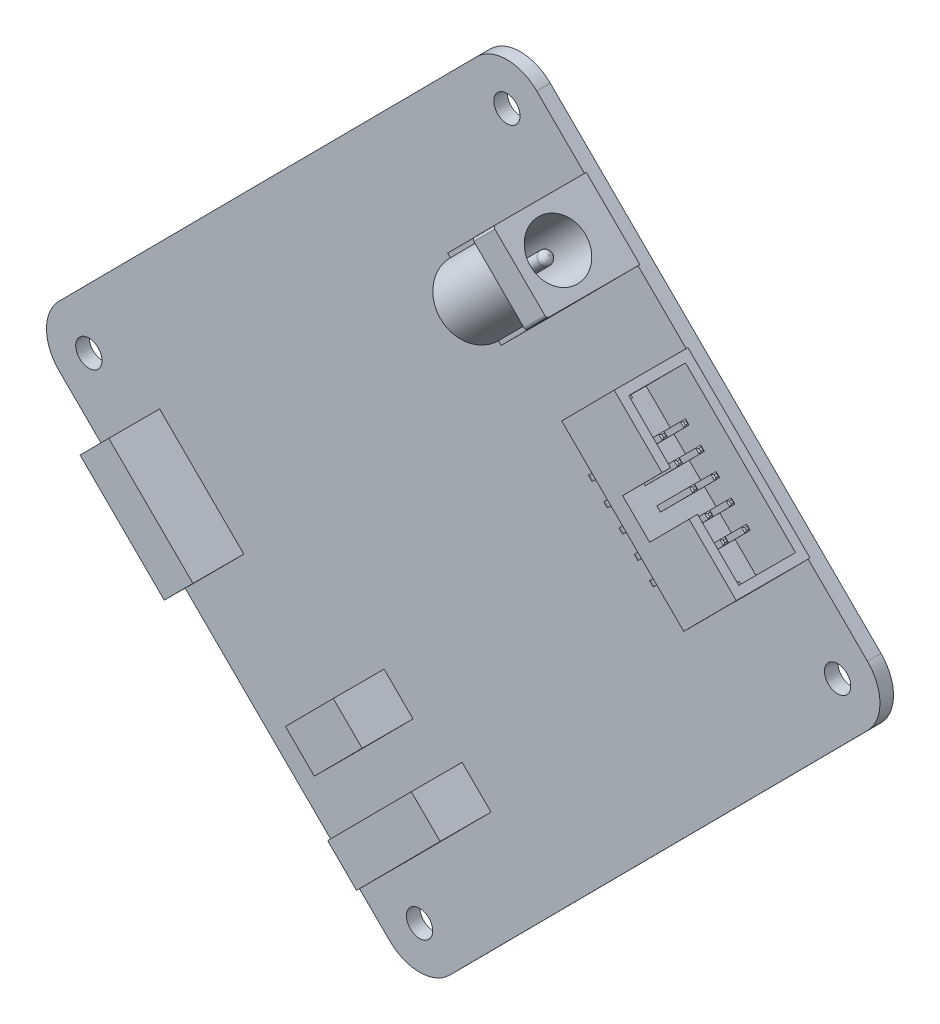
from build123d import *

# Parameters (mm, degrees)
EXTRUDE_1_DEPTH      = 1.6
SKETCH_2_R           = 1.5500000000000003
SKETCH_2_R_2         = 1.5500000000000012
SKETCH_2_R_3         = 1.550000000000001
CUT_EXTRUDE_1_DEPTH  = 1.6
EXTRUDE_2_DEPTH      = 8.7
CUT_EXTRUDE_2_DEPTH  = 6.6
CUT_EXTRUDE_3_DEPTH  = 1.3
CUT_EXTRUDE_4_DEPTH  = 1.3
EXTRUDE_3_DEPTH      = 5.6
EXTRUDE_3_DEPTH_BACK = 4.2
SKETCH_7_W           = 0.6000000000000014
SKETCH_7_H           = 0.5999999999999988
SKETCH_7_W_2         = 0.5999999999999996
SKETCH_7_W_3         = 0.6000000000000001
SKETCH_7_H_2         = 0.5999999999999996
SKETCH_8_W           = 0.6000000000000001
SKETCH_8_H           = 0.5999999999999988
SKETCH_8_W_2         = 0.599999999999997
SKETCH_8_W_3         = 0.5999999999999996
SKETCH_8_W_4         = 0.5999999999999979
EXTRUDE_4_DEPTH      = 2.54
EXTRUDE_5_DEPTH      = 3.06
EXTRUDE_6_DEPTH      = 5.6
FILLET_2_R           = 0.6
CHAMFER_1_SIZE       = 0.15
EXTRUDE_7_DEPTH      = 6
EXTRUDE_8_DEPTH      = 6
EXTRUDE_9_DEPTH      = 11
CUT_EXTRUDE_5_DEPTH  = 10.5
FILLET_3_R           = 0.3
SKETCH_16_R          = 3.2500000000000004
CUT_EXTRUDE_6_DEPTH  = 11.500000000000004
SKETCH_17_R          = 0.7500000000000004
EXTRUDE_10_DEPTH     = 10
FILLET_4_R           = 0.7


with BuildPart() as part:
    # 草图1 → 凸台-拉伸1 (new body)
    with BuildSketch(Plane.XY):
        with BuildLine():
            Line((-46.21911451091363, -2.6230867480424327), (3.1094757757567852, 47.04269805729206))
            ThreePointArc((3.1094757757567852, 47.04269805729206), (6.640000938228831, 48.51919831730715), (10.18050256804291, 47.06678338005377))
            Line((10.18050256804291, 47.06678338005377), (49.20361920080571, 8.30860529766987))
            ThreePointArc((49.20361920080571, 8.30860529766987), (50.680119460820805, 4.778080135197828), (49.22770452356743, 1.2375785053837478))
            Line((49.22770452356743, 1.2375785053837478), (-0.10088576310299377, -48.42820629995073))
            ThreePointArc((-0.10088576310299377, -48.42820629995073), (-3.6314109255750346, -49.904706559965824), (-7.171912555389116, -48.45229162271245))
            Line((-7.171912555389116, -48.45229162271245), (-46.195029188151906, -9.694113540328557))
            ThreePointArc((-46.195029188151906, -9.694113540328557), (-47.671529448167, -6.163588377856511), (-46.21911451091363, -2.6230867480424327))
        make_face()
    extrude(amount=EXTRUDE_1_DEPTH)

    # 草图2 → 切除-拉伸1 (cut)
    with BuildSketch(Plane.XY.offset(1.6)):
        with Locations((6.657031833280706, 43.51922732252991)):
            Circle(SKETCH_2_R)
        with Locations((-42.671558453389764, -6.146557482804635)):
            Circle(SKETCH_2_R_2)
        with Locations((-3.648441820626913, -44.90473556518859)):
            Circle(SKETCH_2_R_3)
        with Locations((45.68014846604356, 4.76104924014595)):
            Circle(SKETCH_2_R_2)
    extrude(amount=-CUT_EXTRUDE_1_DEPTH, mode=Mode.SUBTRACT)

    # 草图3 → 凸台-拉伸2 (add)
    with BuildSketch(Plane.XY.offset(1.6)):
        Polygon((28.02326441802238, 29.767987191737213), (21.82195592484095, 23.524288530495152), (36.22503351838797, 9.218997347360718), (42.426342011569396, 15.462696008602775), align=None)
    extrude(amount=EXTRUDE_2_DEPTH)

    # 草图4 → 切除-拉伸2 (cut)
    with BuildSketch(Plane(origin=(28.799828733701656, 28.996695182368285, 0), x_dir=(0.7095112115047791, -0.7046941469524354, 0), z_dir=(0.7046941469524354, 0.7095112115047791, 0))):
        Polygon((18.205493946977548, -9.299999999999999), (11.35549394697755, -9.299999999999999), (11.35549394697755, -10.3), (6.855493946977551, -10.3), (6.855493946977551, -9.299999999999999), (-0.09450605302244955, -9.299999999999999), (-0.09450605302244955, -2.6), (18.205493946977548, -2.6), align=None)
    extrude(amount=-CUT_EXTRUDE_2_DEPTH, mode=Mode.SUBTRACT)

    # 草图5 → 切除-拉伸3 (cut)
    with BuildSketch(Plane(origin=(13.626513277867756, -13.533999173765512, 0), x_dir=(0, 0, -1), z_dir=(0.7095112115047784, -0.7046941469524362, 0))):
        Polygon((-7.8, 32.06855107034904), (-7.800000000000001, 38.56855107034904), (-4.400000000000001, 38.56855107034904), (-4.4, 32.06855107034904), align=None)
    extrude(amount=-CUT_EXTRUDE_3_DEPTH, mode=Mode.SUBTRACT)

    # 草图6 → 切除-拉伸4 (cut)
    with BuildSketch(Plane(origin=(-0.7765643156792579, 0.7712920093689172, 0), x_dir=(0, 0, 1), z_dir=(-0.7095112115047795, 0.7046941469524352, 0))):
        Polygon((7.8, 32.06855107034904), (4.4, 32.06855107034904), (4.3999999999999995, 38.56855107034904), (7.8, 38.56855107034904), align=None)
    extrude(amount=-CUT_EXTRUDE_4_DEPTH, mode=Mode.SUBTRACT)

    # 草图7 → 凸台-拉伸3 (add, two sides: drawn at the far end of the back side and taken through both)
    with BuildSketch(Plane(origin=(24.148847363815584, 24.313921186436747, 0), x_dir=(0.7095112115047791, -0.7046941469524355, 0), z_dir=(0.7046941469524355, 0.7095112115047791, 0)).offset(-EXTRUDE_3_DEPTH_BACK)):
        with Locations((14.405493946977552, -7.5)):
            Rectangle(SKETCH_7_W, SKETCH_7_H)
        with Locations((11.865493946977551, -7.5)):
            Rectangle(SKETCH_7_W_2, SKETCH_7_H)
        with Locations((9.325493946977552, -7.5)):
            Rectangle(SKETCH_7_W_2, SKETCH_7_H)
        with Locations((6.785493946977553, -7.5)):
            Rectangle(SKETCH_7_W_2, SKETCH_7_H)
        with Locations((4.245493946977553, -7.5)):
            Rectangle(SKETCH_7_W_3, SKETCH_7_H)
        with Locations((11.865493946977551, -4.96)):
            Rectangle(SKETCH_7_W_2, SKETCH_7_H_2)
        with Locations((9.325493946977552, -4.96)):
            Rectangle(SKETCH_7_W_2, SKETCH_7_H_2)
        with Locations((6.785493946977553, -4.96)):
            Rectangle(SKETCH_7_W_2, SKETCH_7_H_2)
        with Locations((4.245493946977553, -4.96)):
            Rectangle(SKETCH_7_W_3, SKETCH_7_H_2)
        with Locations((14.405493946977552, -4.96)):
            Rectangle(SKETCH_7_W, SKETCH_7_H_2)
    extrude(amount=EXTRUDE_3_DEPTH + EXTRUDE_3_DEPTH_BACK)

    # 草图8 → 凸台-拉伸4 (add)
    with BuildSketch(Plane(origin=(21.18913194661535, 21.333974098116673, 0), x_dir=(0.7095112115047791, -0.7046941469524355, 0), z_dir=(-0.7046941469524355, -0.7095112115047791, 0))):
        with Locations((4.245493946977553, 7.5)):
            Rectangle(SKETCH_8_W, SKETCH_8_H)
        with Locations((6.785493946977555, 7.5)):
            Rectangle(SKETCH_8_W_2, SKETCH_8_H)
        with Locations((9.325493946977549, 7.5)):
            Rectangle(SKETCH_8_W_3, SKETCH_8_H)
        with Locations((11.865493946977551, 7.5)):
            Rectangle(SKETCH_8_W_4, SKETCH_8_H)
        with Locations((14.405493946977547, 7.5)):
            Rectangle(SKETCH_8_W_3, SKETCH_8_H)
    extrude(amount=EXTRUDE_4_DEPTH)

    # 草图9 → 凸台-拉伸5 (add)
    with BuildSketch(Plane(origin=(0, 0, 4.66), x_dir=(-1, 0, -2.05e-15), z_dir=(2.05e-15, -2.04e-15, -1))):
        Polygon((-31.622844772711588, 10.971098585637124), (-31.19713804580872, 11.393915073808587), (-31.62284477271158, 11.822531796193495), (-32.04855149961444, 11.399715308022037), align=None)
        Polygon((-29.82068629548945, 12.761021718896309), (-29.39497956858658, 13.183838207067769), (-29.820686295489466, 13.6124549294527), (-30.24639302239233, 13.18963844128124), align=None)
        Polygon((-28.01852781826731, 14.550944852155498), (-27.592821091364442, 14.973761340326956), (-28.018527818267312, 15.402378062711874), (-28.44423454517018, 14.979561574540412), align=None)
        Polygon((-26.216369341045173, 16.340867985414683), (-25.790662614142306, 16.763684473586142), (-26.21636934104517, 17.19230119597105), (-26.64207606794803, 16.769484707799588), align=None)
        Polygon((-24.414210863823033, 18.130791118673862), (-23.988504136920163, 18.553607606845326), (-24.414210863823044, 18.982224329230252), (-24.83991759072591, 18.559407841058793), align=None)
    extrude(amount=EXTRUDE_5_DEPTH)

    # 草图10 → 凸台-拉伸6 (add)
    with BuildSketch(Plane(origin=(0, 0, 7.2), x_dir=(-1, 0, -1.03e-15), z_dir=(1.03e-15, -1.02e-15, -1))):
        Polygon((-29.832921639452397, 9.16894010841499), (-29.40721491254953, 9.591756596586453), (-29.832921639452394, 10.020373318971362), (-30.258628366355257, 9.597556830799897), align=None)
        Polygon((-28.03076316223028, 10.958863241674191), (-27.605056435327413, 11.38167972984565), (-28.030763162230265, 11.810296452230556), (-28.456469889133132, 11.387479964059093), align=None)
        Polygon((-26.22860468500812, 12.748786374933355), (-25.80289795810525, 13.171602863104818), (-26.228604685008126, 13.60021958548974), (-26.654311411910996, 13.17740309731828), align=None)
        Polygon((-24.42644620778598, 14.538709508192541), (-24.00073948088312, 14.961525996363997), (-24.42644620778599, 15.39014271874892), (-24.852152934688856, 14.967326230577465), align=None)
        Polygon((-22.624287730563847, 16.32863264145173), (-22.19858100366098, 16.751449129623193), (-22.624287730563854, 17.180065852008116), (-23.04999445746672, 16.757249363836653), align=None)
    extrude(amount=EXTRUDE_6_DEPTH)

    # 圆角2
    fillet_2_edges = [part.edges().sort_by_distance(p)[0] for p in [
        (29.607832932038022, 12.97242996298204, 5.26),
        (27.805674454815883, 14.762353096241227, 5.26),
        (26.003515977593743, 16.552276229500414, 5.26),
        (24.201357500371603, 18.342199362759597, 5.26),
        (31.409991409260158, 11.182506829722856, 5.26),
        (22.411434367112413, 16.540040885537458, 7.8),
        (24.213592844334556, 14.750117752278271, 7.8),
        (26.01575132155669, 12.96019461901909, 7.8),
        (27.817909798778828, 11.170271485759901, 7.8),
        (29.620068276000964, 9.380348352500718, 7.8),
    ]]
    fillet(fillet_2_edges, radius=FILLET_2_R)

    # 倒角1
    chamfer_1_edges = [part.edges().sort_by_distance(p)[0] for p in [
        (38.31599404939403, 18.135716702469693, 7.8),
        (38.10314068594259, 18.34712494655542, 7.5),
        (38.31599404939403, 18.135716702469693, 7.2),
        (38.52884741284546, 17.924308458383962, 7.5),
        (36.300982208720455, 20.137048079814605, 7.5),
        (36.513835572171885, 19.925639835728877, 7.2),
        (36.72668893562332, 19.71423159164315, 7.5),
        (36.513835572171885, 19.925639835728877, 7.8),
        (34.49882373149832, 21.92697121307379, 7.5),
        (34.71167709494975, 21.715562968988063, 7.2),
        (34.924530458401186, 21.50415472490233, 7.5),
        (34.71167709494975, 21.715562968988063, 7.8),
        (32.696665254276176, 23.716894346332978, 7.5),
        (32.90951861772761, 23.505486102247247, 7.2),
        (33.12237198117904, 23.29407785816152, 7.5),
        (32.90951861772761, 23.505486102247247, 7.8),
        (30.894506777054037, 25.506817479592165, 7.5),
        (31.10736014050547, 25.295409235506433, 7.2),
        (31.320213503956907, 25.084000991420705, 7.5),
        (31.10736014050547, 25.295409235506433, 7.8),
        (36.300982208720455, 20.137048079814605, 4.96),
        (36.513835572171885, 19.925639835728877, 4.66),
        (36.72668893562332, 19.71423159164315, 4.96),
        (36.513835572171885, 19.925639835728877, 5.26),
        (34.49882373149832, 21.92697121307379, 4.96),
        (34.71167709494975, 21.715562968988063, 4.66),
        (34.924530458401186, 21.50415472490233, 4.96),
        (34.71167709494975, 21.715562968988063, 5.26),
        (32.696665254276176, 23.716894346332978, 4.96),
        (32.90951861772761, 23.505486102247247, 4.66),
        (33.12237198117904, 23.29407785816152, 4.96),
        (32.90951861772761, 23.505486102247247, 5.26),
        (30.894506777054037, 25.506817479592165, 4.96),
        (31.10736014050547, 25.295409235506433, 4.66),
        (31.320213503956907, 25.084000991420705, 4.96),
        (31.10736014050547, 25.295409235506433, 5.26),
        (38.10314068594259, 18.34712494655542, 4.96),
        (38.31599404939403, 18.135716702469693, 4.66),
        (38.52884741284546, 17.924308458383962, 4.96),
        (38.31599404939403, 18.135716702469693, 5.26),
    ]]
    chamfer(chamfer_1_edges, length=CHAMFER_1_SIZE)

    # 草图12 → 凸台-拉伸7 (add)
    with BuildSketch(Plane.XY.offset(1.6)):
        Polygon((-34.322448067484615, -7.673762696248741), (-24.3892911064177, -17.53948075358283), (-27.7718230117894, -20.945134568805777), (-37.70497997285631, -11.07941651147168), align=None)
    extrude(amount=EXTRUDE_7_DEPTH)

    # 草图13 → 凸台-拉伸8 (add)
    with BuildSketch(Plane.XY.offset(1.6)):
        Polygon((-5.0819154372935, -39.25273119591208), (4.783802620040595, -29.31957423484517), (1.3781488048176544, -25.93704232947348), (-8.487569252516439, -35.87019929054039), align=None)
        Polygon((-7.831045751087441, -21.018634494463445), (-13.468598926706928, -26.694724186501677), (-10.062945111483986, -30.077256091873373), (-4.4253919358645, -24.401166399835137), align=None)
    extrude(amount=EXTRUDE_8_DEPTH)

    # 草图14 → 凸台-拉伸9 (add)
    with BuildSketch(Plane.XY.offset(1.6)):
        Polygon((22.347174725984143, 35.40554036735669), (12.481456668650054, 25.472383406289776), (6.166806886257514, 31.74416131416645), (16.0325249435916, 41.67731827523336), align=None)
    extrude(amount=EXTRUDE_9_DEPTH)

    # 草图15 → 切除-拉伸5 (cut)
    with BuildSketch(Plane(origin=(18.934110676367542, 19.063538221301393, 0), x_dir=(0.7095112115047795, -0.704694146952435, 0), z_dir=(-0.704694146952435, -0.7095112115047795, 0))):
        with BuildLine():
            Line((-17.54450605302242, 8.1), (-19.312755422996766, 8.1))
            Line((-19.312755422996766, 8.1), (-19.312755422996766, 13.551399082483591))
            Line((-19.312755422996766, 13.551399082483591), (-8.259048102824128, 13.551399082483591))
            Line((-8.259048102824128, 13.551399082483591), (-8.259048102824128, 8.1))
            Line((-8.259048102824128, 8.1), (-9.54450605302242, 8.1))
            ThreePointArc((-9.54450605302242, 8.1), (-13.54450605302242, 12.1), (-17.54450605302242, 8.1))
        make_face()
    extrude(amount=-CUT_EXTRUDE_5_DEPTH, mode=Mode.SUBTRACT)

    # 圆角3
    fillet_3_edges = [part.edges().sort_by_distance(p)[0] for p in [
        (14.79931018642484, 40.435673655100004, 12.6),
        (21.113959968817383, 34.16389574722333, 12.6),
    ]]
    fillet(fillet_3_edges, radius=FILLET_3_R)

    # 草图16 → 切除-拉伸6 (cut)
    with BuildSketch(Plane(origin=(28.79982873370162, 28.996695182368313, 0), x_dir=(0.7095112115047799, -0.7046941469524346, 0), z_dir=(0.7046941469524346, 0.7095112115047799, 0))):
        with Locations(Location((-13.544506053022408, -8.1, 0), (0, 0, 180))):
            Circle(SKETCH_16_R)
    extrude(amount=-CUT_EXTRUDE_6_DEPTH, mode=Mode.SUBTRACT)

    # 草图17 → 凸台-拉伸10 (add)
    with BuildSketch(Plane(origin=(20.69584604374862, 20.837316250063342, 0), x_dir=(0.7095112115047799, -0.7046941469524346, 0), z_dir=(0.7046941469524346, 0.7095112115047799, 0))):
        with Locations(Location((-13.544506053022412, -8.1, 0), (0, 0, 180))):
            Circle(SKETCH_17_R)
    extrude(amount=EXTRUDE_10_DEPTH)

    # 圆角4
    fillet_4_edges = [part.edges().sort_by_distance(p)[0] for p in [
        (18.664942022987795, 36.948641893823535, 8.1),
    ]]
    fillet(fillet_4_edges, radius=FILLET_4_R)


solid = part.part
